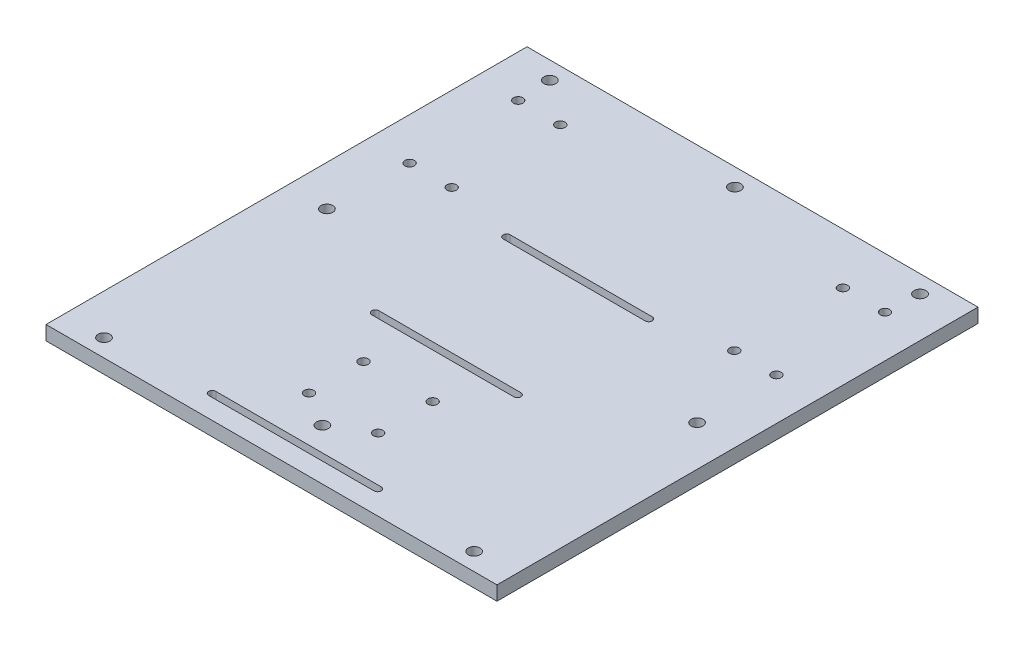
from build123d import *

# Parameters (mm, degrees)
SKETCH2_W           = 190.5
SKETCH2_H           = 203.2
BOSS_EXTRUDE1_DEPTH = 6
SKETCH3_R           = 2
CUT_EXTRUDE2_DEPTH  = 6
CUT_EXTRUDE3_DEPTH  = 7
SKETCH5_R           = 2.5
CUT_EXTRUDE6_DEPTH  = 7
CUT_EXTRUDE12_DEPTH = 10
CUT_EXTRUDE13_DEPTH = 7


with BuildPart() as part:
    # Sketch2 → Boss-Extrude1 (new body)
    with BuildSketch(Plane(origin=(0, 0, 0), x_dir=(1, 0, 0), z_dir=(0, 1, 0))):
        Rectangle(SKETCH2_W, SKETCH2_H)
    extrude(amount=BOSS_EXTRUDE1_DEPTH)

    # Sketch3 → Cut-Extrude2 (cut)
    with BuildSketch(Plane(origin=(0, 6, 0), x_dir=(1, 0, 0), z_dir=(0, 1, 0))):
        with Locations((-77.47, 34.216206602)):
            Circle(SKETCH3_R)
        with Locations((-77.47, 80.0880034)):
            Circle(SKETCH3_R)
        with Locations((77.47, 34.216206602)):
            Circle(SKETCH3_R)
        with Locations((77.47, 80.0880034)):
            Circle(SKETCH3_R)
        with Locations((-59.69, 80.0880034)):
            Circle(SKETCH3_R)
        with Locations((-59.69, 34.216206602)):
            Circle(SKETCH3_R)
        with Locations((59.69, 80.0880034)):
            Circle(SKETCH3_R)
        with Locations((59.69, 34.216206602)):
            Circle(SKETCH3_R)
    extrude(amount=-CUT_EXTRUDE2_DEPTH, mode=Mode.SUBTRACT)

    # Sketch4 → Cut-Extrude3 (cut, through all)
    with BuildSketch(Plane(origin=(0, 6, 0), x_dir=(1, 0, 0), z_dir=(0, 1, 0))):
        with BuildLine():
            Line((-34.925, -90.199433694), (34.925, -90.199433694))
            ThreePointArc((34.925, -90.199433694), (36.425, -91.699433694), (34.925, -93.199433694))
            Line((34.925, -93.199433694), (-34.925, -93.199433694))
            ThreePointArc((-34.925, -93.199433694), (-36.425, -91.699433694), (-34.925, -90.199433694))
        make_face()
    extrude(amount=-CUT_EXTRUDE3_DEPTH, mode=Mode.SUBTRACT)

    # Sketch5 → Cut-Extrude6 (cut, through all)
    with BuildSketch(Plane(origin=(0, 6, 0), x_dir=(1, 0, 0), z_dir=(0, 1, 0))):
        with Locations((-78.187036158, 94.165073798)):
            Circle(SKETCH5_R)
        with Locations((0, 94.165073798)):
            Circle(SKETCH5_R)
        with Locations((78.187036158, 0)):
            Circle(SKETCH5_R)
        with Locations((0, -80.0880034)):
            Circle(SKETCH5_R)
        with Locations((-78.187036158, 0)):
            Circle(SKETCH5_R)
        with Locations((78.187036158, 94.165073798)):
            Circle(SKETCH5_R)
        with Locations((-78.187036158, -94.165073798)):
            Circle(SKETCH5_R)
        with Locations((78.187036158, -94.165073798)):
            Circle(SKETCH5_R)
    extrude(amount=-CUT_EXTRUDE6_DEPTH, mode=Mode.SUBTRACT)

    # Sketch8 → Cut-Extrude12 (cut)
    with BuildSketch(Plane(origin=(0, 6, 0), x_dir=(1, 0, 0), z_dir=(0, 1, 0))):
        with BuildLine():
            Line((-30, 29.25), (30, 29.25))
            ThreePointArc((30, 29.25), (31.5, 27.75), (30, 26.25))
            Line((30, 26.25), (-30, 26.25))
            ThreePointArc((-30, 26.25), (-31.5, 27.75), (-30, 29.25))
        make_face()
        with BuildLine():
            Line((-30, -26.25), (30, -26.25))
            ThreePointArc((30, -26.25), (31.5, -27.75), (30, -29.25))
            Line((30, -29.25), (-30, -29.25))
            ThreePointArc((-30, -29.25), (-31.5, -27.75), (-30, -26.25))
        make_face()
    extrude(amount=-CUT_EXTRUDE12_DEPTH, mode=Mode.SUBTRACT)

    # Sketch9 → Cut-Extrude13 (cut, through all)
    with BuildSketch(Plane(origin=(0, 6, 0), x_dir=(1, 0, 0), z_dir=(0, 1, 0))):
        with BuildLine():
            ThreePointArc((-14.61, -69.152429333), (-16.024213562, -72.566642895), (-12.61, -71.152429333))
            Line((-12.61, -71.152429333), (-14.61, -71.152429333))
            Line((-14.61, -71.152429333), (-14.61, -69.152429333))
        make_face()
        with BuildLine():
            Line((-14.61, -71.152429333), (-12.61, -71.152429333))
            ThreePointArc((-12.61, -71.152429333), (-13.195786438, -69.73821577), (-14.61, -69.152429333))
            Line((-14.61, -69.152429333), (-14.61, -71.152429333))
        make_face()
        with BuildLine():
            ThreePointArc((14.61, -69.152429333), (13.195786438, -69.73821577), (12.61, -71.152429333))
            Line((12.61, -71.152429333), (14.61, -71.152429333))
            Line((14.61, -71.152429333), (14.61, -69.152429333))
        make_face()
        with BuildLine():
            Line((14.61, -71.152429333), (12.61, -71.152429333))
            ThreePointArc((12.61, -71.152429333), (14.61, -73.152429333), (16.61, -71.152429333))
            ThreePointArc((16.61, -71.152429333), (16.024213562, -69.73821577), (14.61, -69.152429333))
            Line((14.61, -69.152429333), (14.61, -71.152429333))
        make_face()
        with BuildLine():
            ThreePointArc((16.61, -48.112429333), (14.61, -46.112429333), (12.61, -48.112429333))
            Line((12.61, -48.112429333), (14.61, -48.112429333))
            Line((14.61, -48.112429333), (14.61, -50.112429333))
            ThreePointArc((14.61, -50.112429333), (16.024213562, -49.526642895), (16.61, -48.112429333))
        make_face()
        with BuildLine():
            Line((14.61, -48.112429333), (12.61, -48.112429333))
            ThreePointArc((12.61, -48.112429333), (13.195786438, -49.526642895), (14.61, -50.112429333))
            Line((14.61, -50.112429333), (14.61, -48.112429333))
        make_face()
        with BuildLine():
            ThreePointArc((-14.61, -50.112429333), (-13.195786438, -49.526642895), (-12.61, -48.112429333))
            Line((-12.61, -48.112429333), (-14.61, -48.112429333))
            Line((-14.61, -48.112429333), (-14.61, -50.112429333))
        make_face()
        with BuildLine():
            Line((-14.61, -48.112429333), (-12.61, -48.112429333))
            ThreePointArc((-12.61, -48.112429333), (-16.024213562, -46.69821577), (-14.61, -50.112429333))
            Line((-14.61, -50.112429333), (-14.61, -48.112429333))
        make_face()
    extrude(amount=-CUT_EXTRUDE13_DEPTH, mode=Mode.SUBTRACT)


solid = part.part
